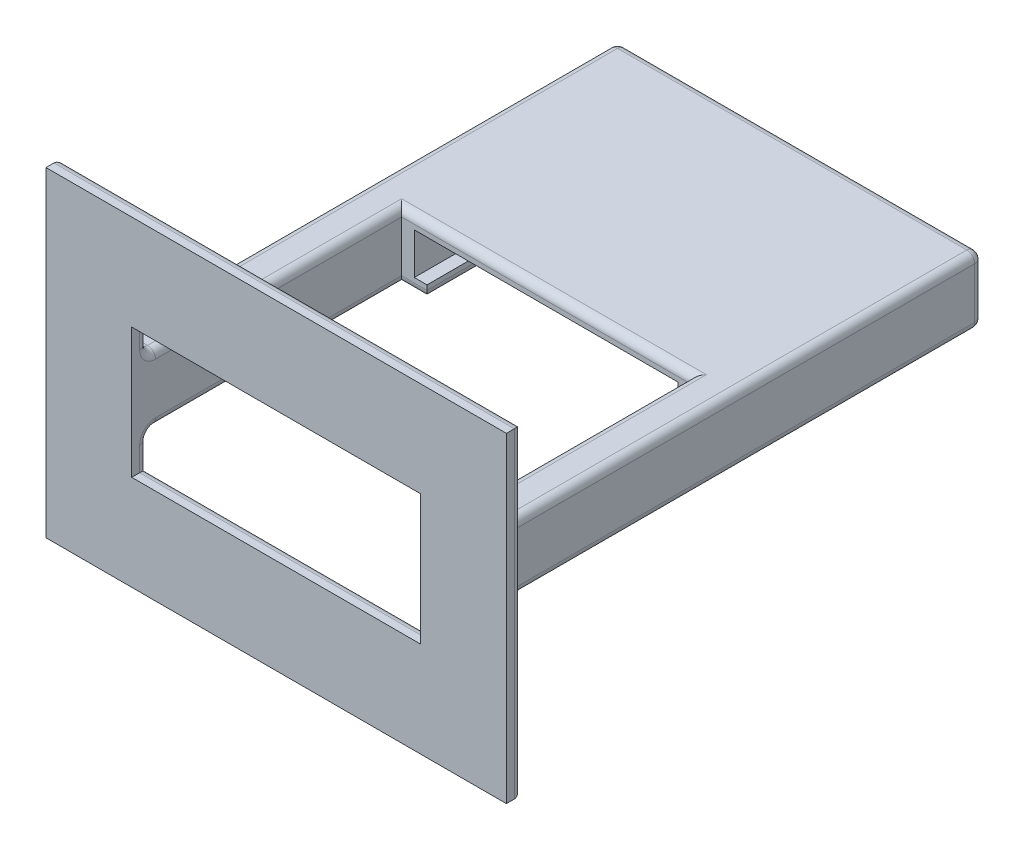
from build123d import *

# Parameters (mm, degrees)
SKETCH1_W                = 36.4
SKETCH1_H                = 75.6
SKETCH1_W_2              = 33.2
SKETCH1_H_2              = 72.4
BOSS_EXTRUDE1_DEPTH      = 5.2
SKETCH2_W                = 36.4
SKETCH2_H                = 75.6
BOSS_EXTRUDE2_DEPTH      = 1.6
BOSS_EXTRUDE3_START      = 5.2
SKETCH2_2_W              = 36.4
SKETCH2_2_H              = 75.6
BOSS_EXTRUDE3_DEPTH      = 1.6
CUT_EXTRUDE1_START       = -1.6
SKETCH3_W                = 33.2
SKETCH3_H                = 1.6
CUT_EXTRUDE1_DEPTH       = 5.2
CUT_EXTRUDE2_DEPTH       = 2
BOSS_EXTRUDE5_DEPTH      = 6.8
BOSS_EXTRUDE5_DEPTH_BACK = 1.6
SKETCH6_W                = 4.8
SKETCH6_H                = 64
SKETCH7_W                = 36.4
SKETCH7_H                = 43.6
CUT_EXTRUDE3_DEPTH       = 12
SKETCH8_W                = 58
SKETCH8_H                = 40.4
SKETCH8_W_2              = 36.4
SKETCH8_H_2              = 16.4
BOSS_EXTRUDE6_DEPTH      = 2
FILLET2_R                = 1


with BuildPart() as part:
    # Sketch1 → Boss-Extrude1 (new body)
    with BuildSketch(Plane(origin=(0, 0, 0), x_dir=(1, 0, 0), z_dir=(0, 1, 0))):
        with Locations((16.6, 36.2)):
            Rectangle(SKETCH1_W, SKETCH1_H)
        with Locations((16.6, 36.2)):
            Rectangle(SKETCH1_W_2, SKETCH1_H_2, mode=Mode.SUBTRACT)
    extrude(amount=BOSS_EXTRUDE1_DEPTH)

    # Sketch2 → Boss-Extrude2 (add)
    with BuildSketch(Plane(origin=(0, 0, 0), x_dir=(1, 0, 0), z_dir=(0, 1, 0))):
        with Locations((16.6, 36.2)):
            Rectangle(SKETCH2_W, SKETCH2_H)
    extrude(amount=-BOSS_EXTRUDE2_DEPTH)

    # Sketch2_2 → Boss-Extrude3 (add)
    with BuildSketch(Plane(origin=(0, 0, 0), x_dir=(1, 0, 0), z_dir=(0, 1, 0)).offset(BOSS_EXTRUDE3_START)):
        with Locations((16.6, 36.2)):
            Rectangle(SKETCH2_2_W, SKETCH2_2_H)
    extrude(amount=BOSS_EXTRUDE3_DEPTH)

    # Sketch3 → Cut-Extrude1 (cut)
    with BuildSketch(Plane(origin=(0, 6.8, 0), x_dir=(1, 0, 0), z_dir=(0, 1, 0)).offset(CUT_EXTRUDE1_START)):
        with Locations((16.6, -0.8)):
            Rectangle(SKETCH3_W, SKETCH3_H)
    extrude(amount=-CUT_EXTRUDE1_DEPTH, mode=Mode.SUBTRACT)

    # Sketch5 → Cut-Extrude2 (cut)
    with BuildSketch(Plane.XZ.offset(1.6)):
        with BuildLine():
            Line((1.6, 1.6), (31.6, 1.6))
            Line((31.6, 1.6), (31.6, -6.4))
            ThreePointArc((31.6, -6.4), (16.6, -21.4), (1.6, -6.4))
            Line((1.6, -6.4), (1.6, 1.6))
        make_face()
    extrude(amount=-CUT_EXTRUDE2_DEPTH, mode=Mode.SUBTRACT)

    # Sketch6 → Boss-Extrude5 (add, two sides: drawn at the far end of the back side and taken through both)
    with BuildSketch(Plane(origin=(0, 0, 0), x_dir=(1, 0, 0), z_dir=(0, 1, 0)).offset(-BOSS_EXTRUDE5_DEPTH_BACK)):
        with Locations((-4, -1.6)):
            Rectangle(SKETCH6_W, SKETCH6_H)
        with Locations((37.2, -1.6)):
            Rectangle(SKETCH6_W, SKETCH6_H)
    extrude(amount=BOSS_EXTRUDE5_DEPTH + BOSS_EXTRUDE5_DEPTH_BACK)

    # Sketch7 → Cut-Extrude3 (cut)
    with BuildSketch(Plane.XZ.offset(1.6)):
        with Locations((16.6, -52.2)):
            Rectangle(SKETCH7_W, SKETCH7_H)
    extrude(amount=-CUT_EXTRUDE3_DEPTH, mode=Mode.SUBTRACT)

    # Sketch8 → Boss-Extrude6 (add)
    with BuildSketch(Plane.XY.offset(33.6)):
        with Locations((16.6, 2.6)):
            Rectangle(SKETCH8_W, SKETCH8_H)
        with Locations((16.6, 2.6)):
            Rectangle(SKETCH8_W_2, SKETCH8_H_2, mode=Mode.SUBTRACT)
    extrude(amount=BOSS_EXTRUDE6_DEPTH)

    # Fillet2
    fillet2_edges = [part.edges().sort_by_distance(p)[0] for p in [
        (16.6, -17.6, 33.6),
        (45.6, 2.6, 33.6),
        (16.6, 22.8, 33.6),
        (-12.4, 2.6, 33.6),
        (-1.6, 8.8, 33.6),
        (16.6, 10.8, 33.6),
        (34.8, 8.8, 33.6),
        (34.8, -3.6, 33.6),
        (16.6, -5.6, 33.6),
        (-1.6, -3.6, 33.6),
        (37.2, 6.8, 33.6),
        (34.8, 6.8, 17.6),
        (16.6, 6.8, 1.6),
        (-1.6, 6.8, 17.6),
        (-4, 6.8, 33.6),
        (16.6, 6.8, -30.4),
        (39.6, 2.6, 33.6),
        (39.6, 6.8, 1.6),
        (39.6, 2.6, -30.4),
        (-4, -1.6, 33.6),
        (-1.6, -1.6, 17.6),
        (0, -1.6, 1.6),
        (1.6, -1.6, -2.4),
        (16.6, -1.6, -21.4),
        (31.6, -1.6, -2.4),
        (33.2, -1.6, 1.6),
        (34.8, -1.6, 17.6),
        (37.2, -1.6, 33.6),
        (39.6, -1.6, 1.6),
        (16.6, -1.6, -30.4),
        (-6.4, -1.6, 1.6),
        (-6.4, 2.6, -30.4),
        (-6.4, 6.8, 1.6),
        (-6.4, 2.6, 33.6),
    ]]
    fillet(fillet2_edges, radius=FILLET2_R)


solid = part.part
